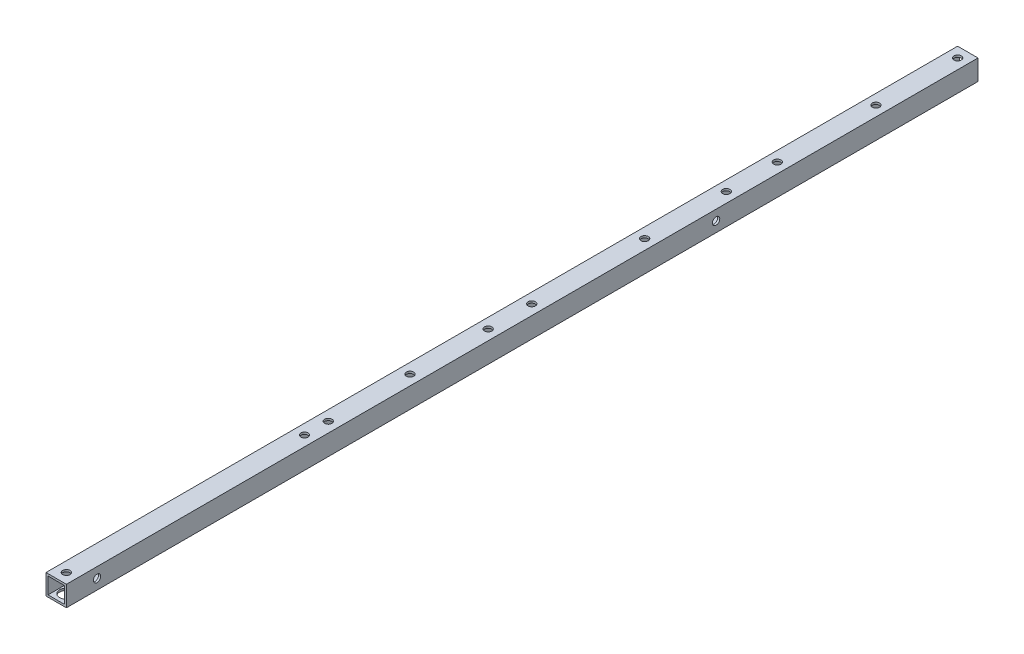
from build123d import *

# Parameters (mm, degrees)
SKETCH_1_W                  = 15
SKETCH_1_H                  = 15
SKETCH_1_W_2                = 12
SKETCH_1_H_2                = 12
EXTRUDE_1_DEPTH             = 670
SKETCH_4_R                  = 2.7
CUT_EXTRUDE_3_DEPTH         = 20
SKETCH_3_R                  = 2.7
CUT_EXTRUDE_4_DEPTH         = 30
SKETCH_5_R                  = 2.7
CUT_EXTRUDE_5_DEPTH         = 40
SKETCH_6_R                  = 5
CUT_EXTRUDE_6_DEPTH         = 10
SKETCH_7_R                  = 5
CUT_EXTRUDE_7_DEPTH         = 10
HOLE_WIZARD_5_4_5_4_1_D     = 5.4
HOLE_WIZARD_10_0_10_1_D     = 10
HOLE_WIZARD_10_0_10_1_DEPTH = 1.5
HOLE_WIZARD_10_0_10_1_TIP   = 3.004303095


with BuildPart() as part:
    # ｽｹｯﾁ1 → ﾎﾞｽ - 押し出し1 (new body)
    with BuildSketch(Plane.XY):
        Rectangle(SKETCH_1_W, SKETCH_1_H)
        Rectangle(SKETCH_1_W_2, SKETCH_1_H_2, mode=Mode.SUBTRACT)
    extrude(amount=EXTRUDE_1_DEPTH)

    # ｽｹｯﾁ4 → ｶｯﾄ - 押し出し3 (cut)
    with BuildSketch(Plane(origin=(7.5, 0, 0), x_dir=(0, 0, -1), z_dir=(1, 0, 0))):
        with Locations((-647.5, 0)):
            Circle(SKETCH_4_R)
        with Locations((-192.5, 0)):
            Circle(SKETCH_4_R)
    extrude(amount=-CUT_EXTRUDE_3_DEPTH, mode=Mode.SUBTRACT)

    # ｽｹｯﾁ3 → ｶｯﾄ - 押し出し4 (cut)
    with BuildSketch(Plane(origin=(0, 7.5, 0), x_dir=(1, 0, 0), z_dir=(0, 1, 0))):
        with Locations((0, -177.5)):
            Circle(SKETCH_3_R)
        with Locations((0, -487.5)):
            Circle(SKETCH_3_R)
        with Locations((0, -352.5)):
            Circle(SKETCH_3_R)
        with Locations((0, -662.5)):
            Circle(SKETCH_3_R)
        with Locations((0, -140)):
            Circle(SKETCH_3_R)
    extrude(amount=-CUT_EXTRUDE_4_DEPTH, mode=Mode.SUBTRACT)

    # ｽｹｯﾁ5 → ｶｯﾄ - 押し出し5 (cut)
    with BuildSketch(Plane(origin=(0, 7.5, 0), x_dir=(1, 0, 0), z_dir=(0, 1, 0))):
        with Locations((0, -7.5)):
            Circle(SKETCH_5_R)
        with Locations((0, -67.5)):
            Circle(SKETCH_5_R)
        with Locations((0, -410)):
            Circle(SKETCH_5_R)
        with Locations((0, -470)):
            Circle(SKETCH_5_R)
    extrude(amount=-CUT_EXTRUDE_5_DEPTH, mode=Mode.SUBTRACT)

    # ｽｹｯﾁ6 → ｶｯﾄ - 押し出し6 (cut)
    with BuildSketch(Plane(origin=(0, -7.5, 0), x_dir=(-1, 0, 0), z_dir=(0, -1, 0))):
        with Locations((0, -662.5)):
            Circle(SKETCH_6_R)
        with Locations((0, -177.5)):
            Circle(SKETCH_6_R)
        with Locations((0, -352.5)):
            Circle(SKETCH_6_R)
        with Locations((0, -487.5)):
            Circle(SKETCH_6_R)
        with Locations((0, -470)):
            Circle(SKETCH_6_R)
        with Locations((0, -410)):
            Circle(SKETCH_6_R)
        with Locations((0, -7.5)):
            Circle(SKETCH_6_R)
        with Locations((0, -67.5)):
            Circle(SKETCH_6_R)
        with Locations((0, -140)):
            Circle(SKETCH_6_R)
    extrude(amount=-CUT_EXTRUDE_6_DEPTH, mode=Mode.SUBTRACT)

    # ｽｹｯﾁ7 → ｶｯﾄ - 押し出し7 (cut)
    with BuildSketch(Plane.ZY.offset(7.5)):
        with Locations((192.5, 0)):
            Circle(SKETCH_7_R)
        with Locations((647.5, 0)):
            Circle(SKETCH_7_R)
    extrude(amount=-CUT_EXTRUDE_7_DEPTH, mode=Mode.SUBTRACT)

    # Ø5.4 (5.4) 直径の穴1 (through all)
    with Locations(Plane(origin=(0, 7.5, 0), x_dir=(1, 0, 0), z_dir=(0, 1, 0))):
        with Locations((0, -237.5), (0, -320.5)):
            Hole(HOLE_WIZARD_5_4_5_4_1_D / 2)

    # Ø10.0 (10) 直径の穴1
    with Locations(Plane(origin=(0, -7.5, 0), x_dir=(-1, 0, 0), z_dir=(0, -1, 0))):
        with Locations((0, -237.5), (0, -320.5)):
            Hole(HOLE_WIZARD_10_0_10_1_D / 2, depth=HOLE_WIZARD_10_0_10_1_DEPTH)
            with Locations((0, 0, -(HOLE_WIZARD_10_0_10_1_DEPTH + HOLE_WIZARD_10_0_10_1_TIP / 2))):  # 118° drill point
                Cone(0, HOLE_WIZARD_10_0_10_1_D / 2, HOLE_WIZARD_10_0_10_1_TIP, mode=Mode.SUBTRACT)


solid = part.part
